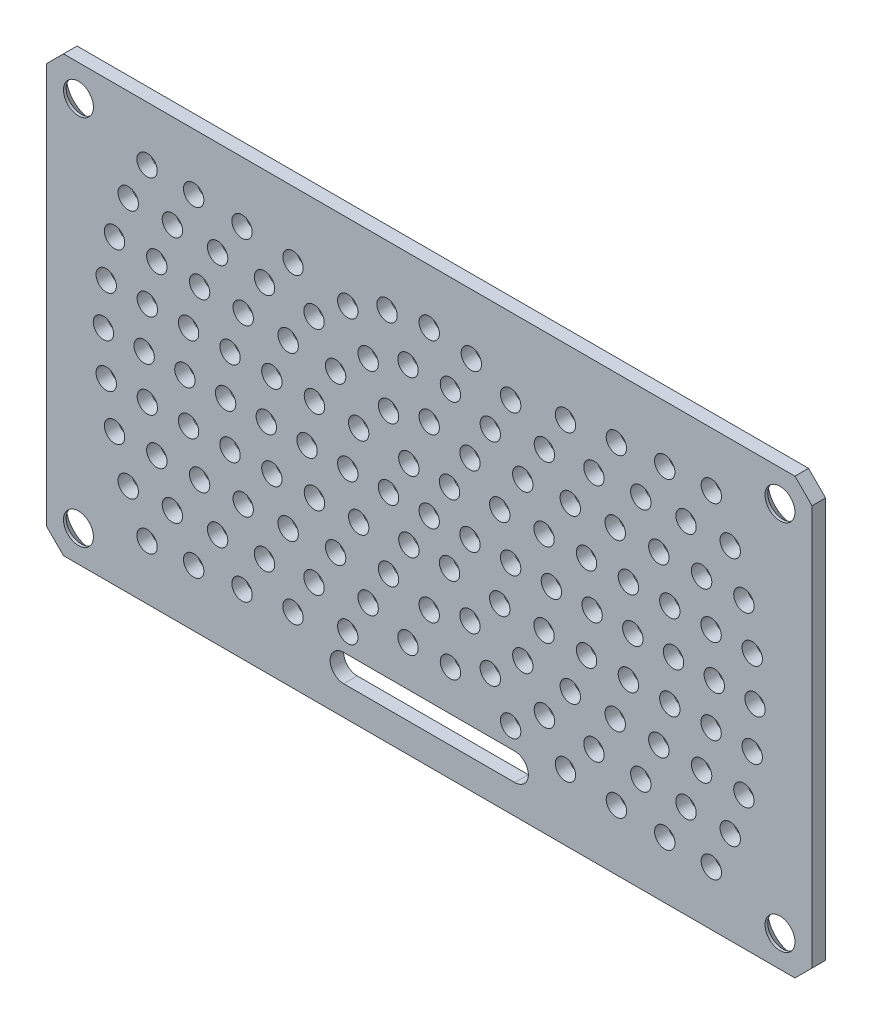
from build123d import *

# Parameters (mm, degrees)
SKETCH1_W           = 89.5
SKETCH1_H           = 50.8
BOSS_EXTRUDE1_DEPTH = 1.5875
CHAMFER1_SIZE       = 2
SKETCH3_R           = 1.75
CUT_EXTRUDE2_DEPTH  = 2.5875
CHAMFER2_SIZE       = 1.27
SKETCH4_R           = 1.190625
CUT_EXTRUDE3_DEPTH  = 2.5875
CUT_EXTRUDE4_DEPTH  = 2.5875


with BuildPart() as part:
    # Sketch1 → Boss-Extrude1 (new body)
    with BuildSketch(Plane.XY):
        with Locations((44.75, 25.4)):
            Rectangle(SKETCH1_W, SKETCH1_H)
    extrude(amount=BOSS_EXTRUDE1_DEPTH)

    # Chamfer1
    chamfer1_edges = [part.edges().sort_by_distance(p)[0] for p in [
        (0, 50.8, 0.79375),
        (89.5, 50.8, 0.79375),
        (89.5, 0, 0.79375),
        (0, 0, 0.79375),
    ]]
    chamfer(chamfer1_edges, length=CHAMFER1_SIZE)

    # Sketch3 → Cut-Extrude2 (cut, through all)
    with BuildSketch(Plane(origin=(0, 0, 0), x_dir=(-1, 0, 0), z_dir=(0, 0, -1))):
        with Locations((-85.75, 47.15)):
            Circle(SKETCH3_R)
        with Locations((-3.75, 47.15)):
            Circle(SKETCH3_R)
        with Locations((-3.75, 3.65)):
            Circle(SKETCH3_R)
        with Locations((-85.75, 3.65)):
            Circle(SKETCH3_R)
    extrude(amount=-CUT_EXTRUDE2_DEPTH, mode=Mode.SUBTRACT)

    # Chamfer2
    chamfer2_edges = [part.edges().sort_by_distance(p)[0] for p in [
        (87.5, 47.15, 0),
        (5.5, 47.15, 0),
        (5.5, 3.65, 0),
        (87.5, 3.65, 0),
    ]]
    chamfer(chamfer2_edges, length=CHAMFER2_SIZE)

    # Sketch4 → Cut-Extrude3 (cut, through all)
    with BuildSketch(Plane(origin=(0, 0, 0), x_dir=(-1, 0, 0), z_dir=(0, 0, -1))):
        with Locations((-44.75, 25.4)):
            Circle(SKETCH4_R)
        with Locations((-39.99, 25.4)):
            Circle(SKETCH4_R)
        with Locations((-35.23, 25.4)):
            Circle(SKETCH4_R)
        with Locations((-30.47, 25.4)):
            Circle(SKETCH4_R)
        with Locations((-25.71, 25.4)):
            Circle(SKETCH4_R)
        with Locations((-20.95, 25.4)):
            Circle(SKETCH4_R)
        with Locations((-16.19, 25.4)):
            Circle(SKETCH4_R)
        with Locations((-11.43, 25.4)):
            Circle(SKETCH4_R)
        with Locations((-6.67, 25.4)):
            Circle(SKETCH4_R)
        with Locations((-42.37, 21.277719078)):
            Circle(SKETCH4_R)
        with Locations((-47.13, 21.277719078)):
            Circle(SKETCH4_R)
        with Locations((-49.51, 25.4)):
            Circle(SKETCH4_R)
        with Locations((-47.13, 29.522280922)):
            Circle(SKETCH4_R)
        with Locations((-42.37, 29.522280922)):
            Circle(SKETCH4_R)
        with Locations((-36.505438156, 20.64)):
            Circle(SKETCH4_R)
        with Locations((-39.99, 17.155438156)):
            Circle(SKETCH4_R)
        with Locations((-44.75, 15.88)):
            Circle(SKETCH4_R)
        with Locations((-49.51, 17.155438156)):
            Circle(SKETCH4_R)
        with Locations((-52.994561844, 20.64)):
            Circle(SKETCH4_R)
        with Locations((-54.27, 25.4)):
            Circle(SKETCH4_R)
        with Locations((-52.994561844, 30.16)):
            Circle(SKETCH4_R)
        with Locations((-49.51, 33.644561844)):
            Circle(SKETCH4_R)
        with Locations((-44.75, 34.92)):
            Circle(SKETCH4_R)
        with Locations((-39.99, 33.644561844)):
            Circle(SKETCH4_R)
        with Locations((-36.505438156, 30.16)):
            Circle(SKETCH4_R)
        with Locations((-31.331189375, 20.515952353)):
            Circle(SKETCH4_R)
        with Locations((-33.810885352, 16.220992934)):
            Circle(SKETCH4_R)
        with Locations((-37.61, 13.033157234)):
            Circle(SKETCH4_R)
        with Locations((-42.270304023, 11.336945287)):
            Circle(SKETCH4_R)
        with Locations((-47.229695977, 11.336945287)):
            Circle(SKETCH4_R)
        with Locations((-51.89, 13.033157234)):
            Circle(SKETCH4_R)
        with Locations((-55.689114648, 16.220992934)):
            Circle(SKETCH4_R)
        with Locations((-58.168810625, 20.515952353)):
            Circle(SKETCH4_R)
        with Locations((-59.03, 25.4)):
            Circle(SKETCH4_R)
        with Locations((-58.168810625, 30.284047647)):
            Circle(SKETCH4_R)
        with Locations((-55.689114648, 34.579007066)):
            Circle(SKETCH4_R)
        with Locations((-51.89, 37.766842766)):
            Circle(SKETCH4_R)
        with Locations((-47.229695977, 39.463054713)):
            Circle(SKETCH4_R)
        with Locations((-42.270304023, 39.463054713)):
            Circle(SKETCH4_R)
        with Locations((-37.61, 37.766842766)):
            Circle(SKETCH4_R)
        with Locations((-33.810885352, 34.579007066)):
            Circle(SKETCH4_R)
        with Locations((-31.331189375, 30.284047647)):
            Circle(SKETCH4_R)
        with Locations((-26.358772267, 20.472085381)):
            Circle(SKETCH4_R)
        with Locations((-28.260876312, 15.88)):
            Circle(SKETCH4_R)
        with Locations((-31.286686886, 11.936686886)):
            Circle(SKETCH4_R)
        with Locations((-35.23, 8.910876312)):
            Circle(SKETCH4_R)
        with Locations((-54.27, 8.910876312)):
            Circle(SKETCH4_R)
        with Locations((-58.213313114, 11.936686886)):
            Circle(SKETCH4_R)
        with Locations((-61.239123688, 15.88)):
            Circle(SKETCH4_R)
        with Locations((-63.141227733, 20.472085381)):
            Circle(SKETCH4_R)
        with Locations((-63.79, 25.4)):
            Circle(SKETCH4_R)
        with Locations((-63.141227733, 30.327914619)):
            Circle(SKETCH4_R)
        with Locations((-61.239123688, 34.92)):
            Circle(SKETCH4_R)
        with Locations((-58.213313114, 38.863313114)):
            Circle(SKETCH4_R)
        with Locations((-54.27, 41.889123688)):
            Circle(SKETCH4_R)
        with Locations((-49.677914619, 43.791227733)):
            Circle(SKETCH4_R)
        with Locations((-44.75, 44.44)):
            Circle(SKETCH4_R)
        with Locations((-39.822085381, 43.791227733)):
            Circle(SKETCH4_R)
        with Locations((-35.23, 41.889123688)):
            Circle(SKETCH4_R)
        with Locations((-31.286686886, 38.863313114)):
            Circle(SKETCH4_R)
        with Locations((-28.260876312, 34.92)):
            Circle(SKETCH4_R)
        with Locations((-26.358772267, 30.327914619)):
            Circle(SKETCH4_R)
        with Locations((-21.470087103, 20.451701759)):
            Circle(SKETCH4_R)
        with Locations((-23.007618108, 15.719667895)):
            Circle(SKETCH4_R)
        with Locations((-25.495395534, 11.410710995)):
            Circle(SKETCH4_R)
        with Locations((-28.824691569, 7.713153154)):
            Circle(SKETCH4_R)
        with Locations((-60.675308431, 7.713153154)):
            Circle(SKETCH4_R)
        with Locations((-64.004604466, 11.410710995)):
            Circle(SKETCH4_R)
        with Locations((-66.492381892, 15.719667895)):
            Circle(SKETCH4_R)
        with Locations((-68.029912897, 20.451701759)):
            Circle(SKETCH4_R)
        with Locations((-68.55, 25.4)):
            Circle(SKETCH4_R)
        with Locations((-68.029912897, 30.348298241)):
            Circle(SKETCH4_R)
        with Locations((-66.492381892, 35.080332105)):
            Circle(SKETCH4_R)
        with Locations((-64.004604466, 39.389289005)):
            Circle(SKETCH4_R)
        with Locations((-60.675308431, 43.086846846)):
            Circle(SKETCH4_R)
        with Locations((-28.824691569, 43.086846846)):
            Circle(SKETCH4_R)
        with Locations((-25.495395534, 39.389289005)):
            Circle(SKETCH4_R)
        with Locations((-23.007618108, 35.080332105)):
            Circle(SKETCH4_R)
        with Locations((-21.470087103, 30.348298241)):
            Circle(SKETCH4_R)
        with Locations((-16.623890574, 20.440608046)):
            Circle(SKETCH4_R)
        with Locations((-17.91237875, 15.631904707)):
            Circle(SKETCH4_R)
        with Locations((-20.016314468, 11.12)):
            Circle(SKETCH4_R)
        with Locations((-22.871770705, 7.041985867)):
            Circle(SKETCH4_R)
        with Locations((-66.628229295, 7.041985867)):
            Circle(SKETCH4_R)
        with Locations((-69.483685532, 11.12)):
            Circle(SKETCH4_R)
        with Locations((-71.58762125, 15.631904707)):
            Circle(SKETCH4_R)
        with Locations((-72.876109426, 20.440608046)):
            Circle(SKETCH4_R)
        with Locations((-73.31, 25.4)):
            Circle(SKETCH4_R)
        with Locations((-72.876109426, 30.359391954)):
            Circle(SKETCH4_R)
        with Locations((-71.58762125, 35.168095293)):
            Circle(SKETCH4_R)
        with Locations((-69.483685532, 39.68)):
            Circle(SKETCH4_R)
        with Locations((-66.628229295, 43.758014133)):
            Circle(SKETCH4_R)
        with Locations((-22.871770705, 43.758014133)):
            Circle(SKETCH4_R)
        with Locations((-20.016314468, 39.68)):
            Circle(SKETCH4_R)
        with Locations((-17.91237875, 35.168095293)):
            Circle(SKETCH4_R)
        with Locations((-16.623890574, 30.359391954)):
            Circle(SKETCH4_R)
        with Locations((-11.80215687, 20.433911691)):
            Circle(SKETCH4_R)
        with Locations((-12.910314111, 15.578757589)):
            Circle(SKETCH4_R)
        with Locations((-14.729717321, 10.942993813)):
            Circle(SKETCH4_R)
        with Locations((-17.21972404, 6.630175665)):
            Circle(SKETCH4_R)
        with Locations((-72.28027596, 6.630175665)):
            Circle(SKETCH4_R)
        with Locations((-74.770282679, 10.942993813)):
            Circle(SKETCH4_R)
        with Locations((-76.589685889, 15.578757589)):
            Circle(SKETCH4_R)
        with Locations((-77.69784313, 20.433911691)):
            Circle(SKETCH4_R)
        with Locations((-78.07, 25.4)):
            Circle(SKETCH4_R)
        with Locations((-77.69784313, 30.366088309)):
            Circle(SKETCH4_R)
        with Locations((-76.589685889, 35.221242411)):
            Circle(SKETCH4_R)
        with Locations((-74.770282679, 39.857006187)):
            Circle(SKETCH4_R)
        with Locations((-72.28027596, 44.169824335)):
            Circle(SKETCH4_R)
        with Locations((-17.21972404, 44.169824335)):
            Circle(SKETCH4_R)
        with Locations((-14.729717321, 39.857006187)):
            Circle(SKETCH4_R)
        with Locations((-12.910314111, 35.221242411)):
            Circle(SKETCH4_R)
        with Locations((-11.80215687, 30.366088309)):
            Circle(SKETCH4_R)
        with Locations((-6.995779679, 20.4295626)):
            Circle(SKETCH4_R)
        with Locations((-7.967544535, 15.544170762)):
            Circle(SKETCH4_R)
        with Locations((-9.568667402, 10.827414896)):
            Circle(SKETCH4_R)
        with Locations((-11.771752624, 6.36)):
            Circle(SKETCH4_R)
        with Locations((-77.728247376, 6.36)):
            Circle(SKETCH4_R)
        with Locations((-79.931332598, 10.827414896)):
            Circle(SKETCH4_R)
        with Locations((-81.532455465, 15.544170762)):
            Circle(SKETCH4_R)
        with Locations((-82.504220321, 20.4295626)):
            Circle(SKETCH4_R)
        with Locations((-82.83, 25.4)):
            Circle(SKETCH4_R)
        with Locations((-82.504220321, 30.3704374)):
            Circle(SKETCH4_R)
        with Locations((-81.532455465, 35.255829238)):
            Circle(SKETCH4_R)
        with Locations((-79.931332598, 39.972585104)):
            Circle(SKETCH4_R)
        with Locations((-77.728247376, 44.44)):
            Circle(SKETCH4_R)
        with Locations((-11.771752624, 44.44)):
            Circle(SKETCH4_R)
        with Locations((-9.568667402, 39.972585104)):
            Circle(SKETCH4_R)
        with Locations((-7.967544535, 35.255829238)):
            Circle(SKETCH4_R)
        with Locations((-6.995779679, 30.3704374)):
            Circle(SKETCH4_R)
    extrude(amount=-CUT_EXTRUDE3_DEPTH, mode=Mode.SUBTRACT)

    # Sketch5 → Cut-Extrude4 (cut, through all)
    with BuildSketch(Plane(origin=(0, 0, 0), x_dir=(-1, 0, 0), z_dir=(0, 0, -1))):
        with BuildLine():
            Line((-54.75, 6.5875), (-34.75, 6.5875))
            ThreePointArc((-34.75, 6.5875), (-33.1625, 5), (-34.75, 3.4125))
            Line((-34.75, 3.4125), (-54.75, 3.4125))
            ThreePointArc((-54.75, 3.4125), (-56.3375, 5), (-54.75, 6.5875))
        make_face()
    extrude(amount=-CUT_EXTRUDE4_DEPTH, mode=Mode.SUBTRACT)


solid = part.part
